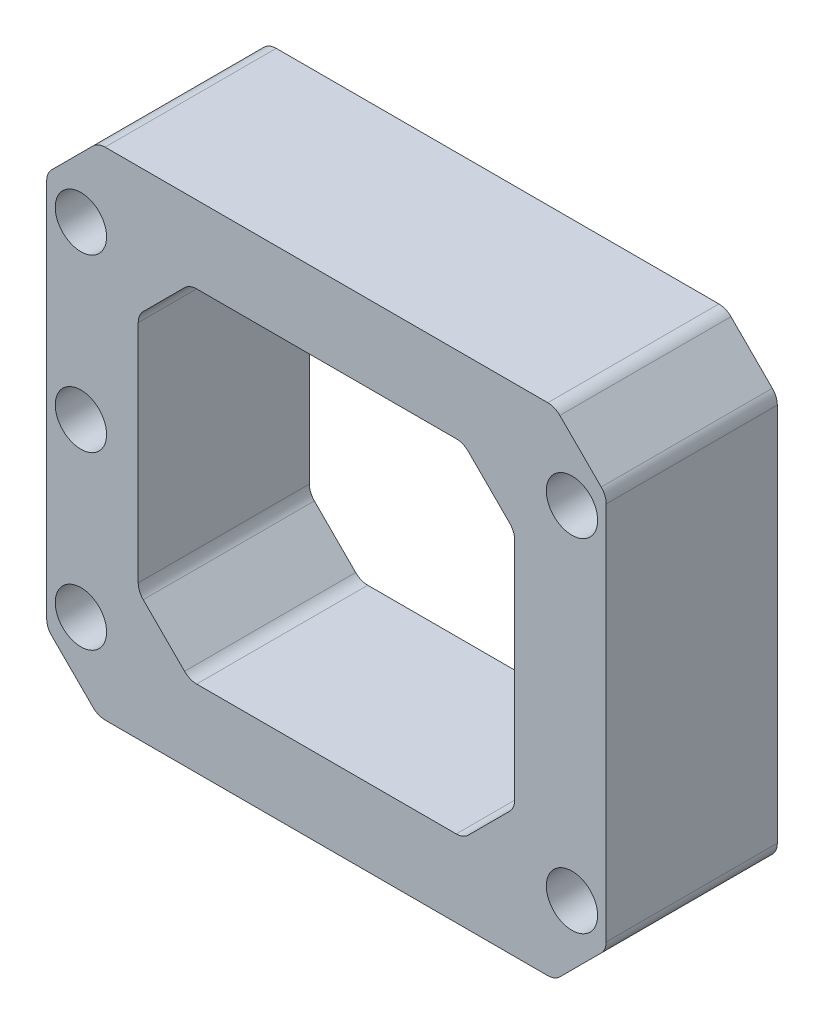
from build123d import *

# Parameters (mm, degrees)
SKETCH_1_W          = 32.7
SKETCH_1_H          = 29
SKETCH_1_R          = 1.5
EXTRUDE_1_DEPTH     = 10
CHAMFER_1_SIZE      = 3
CUT_EXTRUDE_1_DEPTH = 11
FILLET_1_R          = 1


with BuildPart() as part:
    # 草图1 → 凸台-拉伸1 (new body)
    with BuildSketch(Plane.XY):
        Rectangle(SKETCH_1_W, SKETCH_1_H)
        with Locations((-14.35, -10)):
            Circle(SKETCH_1_R, mode=Mode.SUBTRACT)
        with Locations((-14.35, 10)):
            Circle(SKETCH_1_R, mode=Mode.SUBTRACT)
        with Locations((14.35, 10)):
            Circle(SKETCH_1_R, mode=Mode.SUBTRACT)
        with Locations((14.35, -10)):
            Circle(SKETCH_1_R, mode=Mode.SUBTRACT)
        with Locations((-14.35, 0)):
            Circle(SKETCH_1_R, mode=Mode.SUBTRACT)
    extrude(amount=EXTRUDE_1_DEPTH)

    # 倒角1
    chamfer_1_edges = [part.edges().sort_by_distance(p)[0] for p in [
        (16.35, -14.5, 5),
        (-16.35, -14.5, 5),
        (-16.35, 14.5, 5),
        (16.35, 14.5, 5),
    ]]
    chamfer(chamfer_1_edges, length=CHAMFER_1_SIZE)

    # 草图2 → 切除-拉伸1 (cut, through all)
    with BuildSketch(Plane.XY.offset(10)):
        Polygon((-11, 7), (-8, 10), (8, 10), (11, 7), (11, -7), (8, -10), (-8, -10), (-11, -7), align=None)
    extrude(amount=-CUT_EXTRUDE_1_DEPTH, mode=Mode.SUBTRACT)

    # 圆角1
    fillet_1_edges = [part.edges().sort_by_distance(p)[0] for p in [
        (16.35, 11.5, 5),
        (16.35, -11.5, 5),
        (-13.35, -14.5, 5),
        (13.35, -14.5, 5),
        (-13.35, 14.5, 5),
        (13.35, 14.5, 5),
        (-16.35, 11.5, 5),
        (-16.35, -11.5, 5),
        (-8, 10, 5),
        (8, 10, 5),
        (11, 7, 5),
        (11, -7, 5),
        (8, -10, 5),
        (-8, -10, 5),
        (-11, -7, 5),
        (-11, 7, 5),
    ]]
    fillet(fillet_1_edges, radius=FILLET_1_R)


solid = part.part
